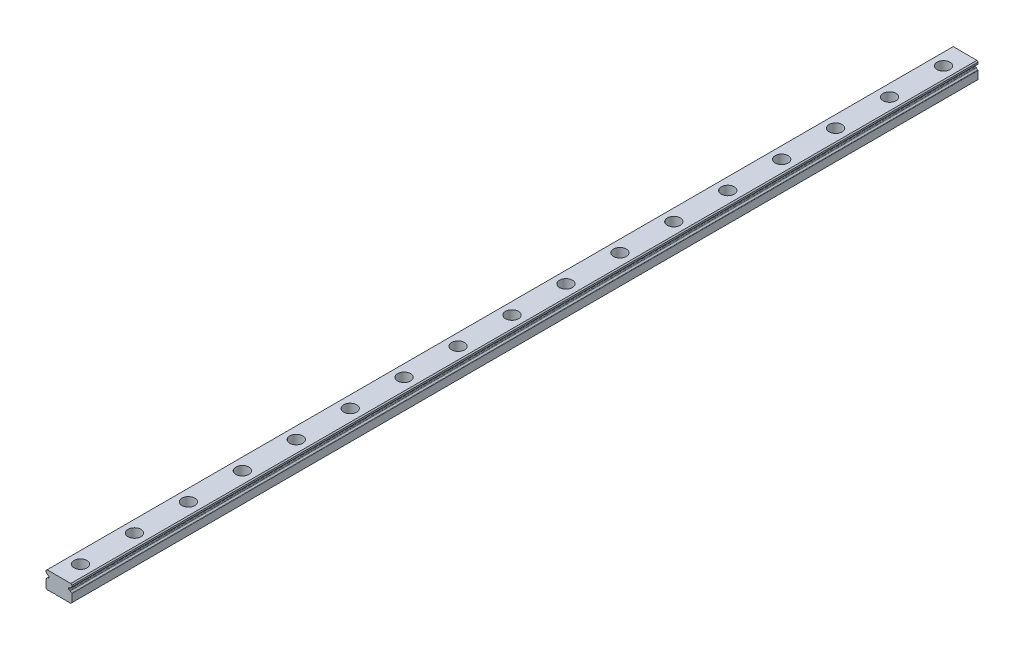
from build123d import *

# Parameters (mm, degrees)
BOSS_EXTRUDE1_DEPTH = 420
SKETCH2_R           = 1.75
CUT_EXTRUDE1_DEPTH  = 8.999998
SKETCH2_3_R         = 3
CUT_EXTRUDE2_DEPTH  = 4.5


with BuildPart() as part:
    # Sketch1 → Boss-Extrude1 (new body)
    with BuildSketch(Plane.XY):
        with BuildLine():
            Line((5.5, -7.999998), (6, -7.499998))
            Line((6, -7.499998), (6, -3.85787958))
            ThreePointArc((6, -3.85787958), (5.9576137, -3.718608076), (5.844827586, -3.626562203))
            ThreePointArc((5.844827586, -3.626562203), (5.51524529, -3.424071402), (5.267205011, -3.12724985))
            ThreePointArc((5.267205011, -3.12724985), (5.185241933, -3.042985123), (5.073828324, -3.005495145))
            Line((5.073828324, -3.005495145), (4.728211064, -2.975257553))
            ThreePointArc((4.728211064, -2.975257553), (4.565680666, -2.89510643), (4.5, -2.726208878))
            Line((4.5, -2.726208878), (4.5, -2.273787121))
            ThreePointArc((4.5, -2.273787121), (4.565680666, -2.10488957), (4.728211064, -2.024738447))
            Line((4.728211064, -2.024738447), (5.09477657, -1.992668121))
            ThreePointArc((5.09477657, -1.992668121), (5.203244499, -1.957004425), (5.284541491, -1.876829678))
            ThreePointArc((5.284541491, -1.876829678), (5.527906161, -1.597614221), (5.844827586, -1.405915383))
            ThreePointArc((5.844827586, -1.405915383), (5.9576137, -1.31386951), (6, -1.174598006))
            Line((6, -1.174598006), (6, -0.5))
            Line((6, -0.5), (5.5, 0))
            Line((5.5, 0), (-5.5, 0))
            Line((-5.5, 0), (-6, -0.5))
            Line((-6, -0.5), (-6, -1.174598006))
            ThreePointArc((-6, -1.174598006), (-5.9576137, -1.31386951), (-5.844827586, -1.405915383))
            ThreePointArc((-5.844827586, -1.405915383), (-5.527906161, -1.597614221), (-5.284541491, -1.876829678))
            ThreePointArc((-5.284541491, -1.876829678), (-5.203244499, -1.957004425), (-5.09477657, -1.992668121))
            Line((-5.09477657, -1.992668121), (-4.728211064, -2.024738447))
            ThreePointArc((-4.728211064, -2.024738447), (-4.565680666, -2.10488957), (-4.5, -2.273787121))
            Line((-4.5, -2.273787121), (-4.5, -2.726208878))
            ThreePointArc((-4.5, -2.726208878), (-4.565680666, -2.89510643), (-4.728211064, -2.975257553))
            Line((-4.728211064, -2.975257553), (-5.073828324, -3.005495145))
            ThreePointArc((-5.073828324, -3.005495145), (-5.185241932, -3.042985123), (-5.267205011, -3.12724985))
            ThreePointArc((-5.267205011, -3.12724985), (-5.51524529, -3.424071402), (-5.844827586, -3.626562203))
            ThreePointArc((-5.844827586, -3.626562203), (-5.9576137, -3.718608076), (-6, -3.85787958))
            Line((-6, -3.85787958), (-6, -7.499998))
            Line((-6, -7.499998), (-5.5, -7.999998))
            Line((-5.5, -7.999998), (-2.4, -7.999998))
            ThreePointArc((-2.4, -7.999998), (-2, -7.799998), (-1.6, -7.999998))
            Line((-1.6, -7.999998), (5.5, -7.999998))
        make_face()
    extrude(amount=BOSS_EXTRUDE1_DEPTH)

    # Sketch2 → Cut-Extrude1 (cut, through all)
    with BuildSketch(Plane(origin=(0, 0, 0), x_dir=(1, 0, 0), z_dir=(0, 1, 0))):
        with Locations((0, -10)):
            Circle(SKETCH2_R)
        with Locations((0, -35)):
            Circle(SKETCH2_R)
        with Locations((0, -60)):
            Circle(SKETCH2_R)
        with Locations((0, -85)):
            Circle(SKETCH2_R)
        with Locations((0, -110)):
            Circle(SKETCH2_R)
        with Locations((0, -135)):
            Circle(SKETCH2_R)
        with Locations((0, -160)):
            Circle(SKETCH2_R)
        with Locations((0, -185)):
            Circle(SKETCH2_R)
        with Locations((0, -210)):
            Circle(SKETCH2_R)
        with Locations((0, -235)):
            Circle(SKETCH2_R)
        with Locations((0, -260)):
            Circle(SKETCH2_R)
        with Locations((0, -285)):
            Circle(SKETCH2_R)
        with Locations((0, -310)):
            Circle(SKETCH2_R)
        with Locations((0, -335)):
            Circle(SKETCH2_R)
        with Locations((0, -360)):
            Circle(SKETCH2_R)
        with Locations((0, -385)):
            Circle(SKETCH2_R)
        with Locations((0, -410)):
            Circle(SKETCH2_R)
    extrude(amount=-CUT_EXTRUDE1_DEPTH, mode=Mode.SUBTRACT)

    # Sketch2_3 → Cut-Extrude2 (cut)
    with BuildSketch(Plane(origin=(0, 0, 0), x_dir=(1, 0, 0), z_dir=(0, 1, 0))):
        with Locations((0, -10)):
            Circle(SKETCH2_3_R)
        with Locations((0, -35)):
            Circle(SKETCH2_3_R)
        with Locations((0, -60)):
            Circle(SKETCH2_3_R)
        with Locations((0, -85)):
            Circle(SKETCH2_3_R)
        with Locations((0, -110)):
            Circle(SKETCH2_3_R)
        with Locations((0, -135)):
            Circle(SKETCH2_3_R)
        with Locations((0, -160)):
            Circle(SKETCH2_3_R)
        with Locations((0, -185)):
            Circle(SKETCH2_3_R)
        with Locations((0, -210)):
            Circle(SKETCH2_3_R)
        with Locations((0, -235)):
            Circle(SKETCH2_3_R)
        with Locations((0, -260)):
            Circle(SKETCH2_3_R)
        with Locations((0, -285)):
            Circle(SKETCH2_3_R)
        with Locations((0, -310)):
            Circle(SKETCH2_3_R)
        with Locations((0, -335)):
            Circle(SKETCH2_3_R)
        with Locations((0, -360)):
            Circle(SKETCH2_3_R)
        with Locations((0, -385)):
            Circle(SKETCH2_3_R)
        with Locations((0, -410)):
            Circle(SKETCH2_3_R)
    extrude(amount=-CUT_EXTRUDE2_DEPTH, mode=Mode.SUBTRACT)


solid = part.part
